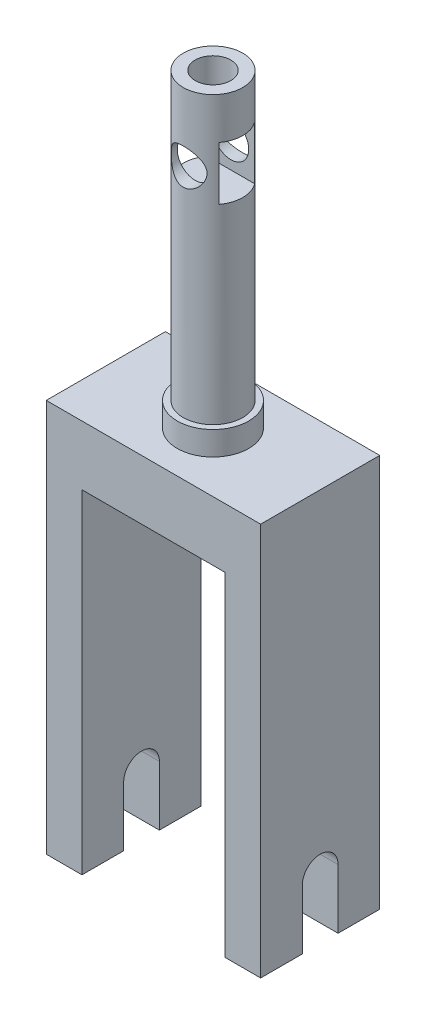
from build123d import *

# Parameters (mm, degrees)
EXTRUDE_1_DEPTH          = 10
CUT_EXTRUDE_1_DEPTH      = 19
SKETCH_9_R               = 3
EXTRUDE_2_DEPTH          = 2
SKETCH_11_R              = 2.5
EXTRUDE_4_DEPTH          = 24
SKETCH_12_W              = 3
SKETCH_12_H              = 4.5
CUT_EXTRUDE_2_DEPTH      = 4
CUT_EXTRUDE_2_DEPTH_BACK = 16
CUT_EXTRUDE_3_REACH      = 61
SKETCH_13_R              = 1.5
SKETCH_15_R              = 1.5
CUT_EXTRUDE_4_DEPTH      = 5


with BuildPart() as part:
    # 草图1 → 凸台-拉伸1 (new body)
    with BuildSketch(Plane.XY):
        Polygon((-15, -25.086741331), (-15, 7.913258669), (3, 7.913258669), (3, -25.086741331), (0, -25.086741331), (0, 2.913258669), (-12, 2.913258669), (-12, -25.086741331), align=None)
    extrude(amount=EXTRUDE_1_DEPTH)

    # 草图2 → 切除-拉伸1 (cut, through all)
    with BuildSketch(Plane(origin=(3, 0, 0), x_dir=(0, 0, -1), z_dir=(1, 0, 0))):
        with BuildLine():
            Line((-6.5, -20.086741331), (-6.5, -25.086741331))
            Line((-6.5, -25.086741331), (-3.5, -25.086741331))
            Line((-3.5, -25.086741331), (-3.5, -20.086741331))
            ThreePointArc((-3.5, -20.086741331), (-5, -18.586741331), (-6.5, -20.086741331))
        make_face()
    extrude(amount=-CUT_EXTRUDE_1_DEPTH, mode=Mode.SUBTRACT)

    # 草图9 → 凸台-拉伸2 (add)
    with BuildSketch(Plane(origin=(0, 7.913258669, 0), x_dir=(1, 0, 0), z_dir=(0, 1, 0))):
        with Locations((-6, -5)):
            Circle(SKETCH_9_R)
    extrude(amount=EXTRUDE_2_DEPTH)

    # 草图11 → 凸台-拉伸4 (add)
    with BuildSketch(Plane(origin=(0, 9.913258669, 0), x_dir=(1, 0, 0), z_dir=(0, 1, 0))):
        with Locations((-6, -5)):
            Circle(SKETCH_11_R)
    extrude(amount=EXTRUDE_4_DEPTH)

    # 草图12 → 切除-拉伸2 (cut, two sides)
    with BuildSketch(Plane(origin=(0, 0, 0), x_dir=(0, 0, -1), z_dir=(1, 0, 0))) as cut_extrude_2_sk:
        with Locations((-5, 28.163258669)):
            Rectangle(SKETCH_12_W, SKETCH_12_H)
    extrude(amount=CUT_EXTRUDE_2_DEPTH, mode=Mode.SUBTRACT)
    extrude(cut_extrude_2_sk.sketch, amount=-CUT_EXTRUDE_2_DEPTH_BACK, mode=Mode.SUBTRACT)

    # 草图13 → 切除-拉伸3 (cut, up to next)
    with BuildSketch(Plane(origin=(0, 33.913258669, 0), x_dir=(-1, 0, 0), z_dir=(0, 1, 0)), mode=Mode.PRIVATE) as cut_extrude_3_sk1:
        with Locations((6, 5)):
            Circle(SKETCH_13_R)
    cut_extrude_3_tool1 = extrude(cut_extrude_3_sk1.sketch, amount=-CUT_EXTRUDE_3_REACH, mode=Mode.PRIVATE) & part.part
    add(cut_extrude_3_tool1.solids().sort_by_distance((-6, 33.913259, 5))[0], mode=Mode.SUBTRACT)

    # 草图15 → 切除-拉伸4 (cut, symmetric)
    with BuildSketch(Plane.XY.offset(5)):
        with Locations((-6, 28.163258669)):
            Circle(SKETCH_15_R)
    extrude(amount=CUT_EXTRUDE_4_DEPTH, both=True, mode=Mode.SUBTRACT)


solid = part.part
